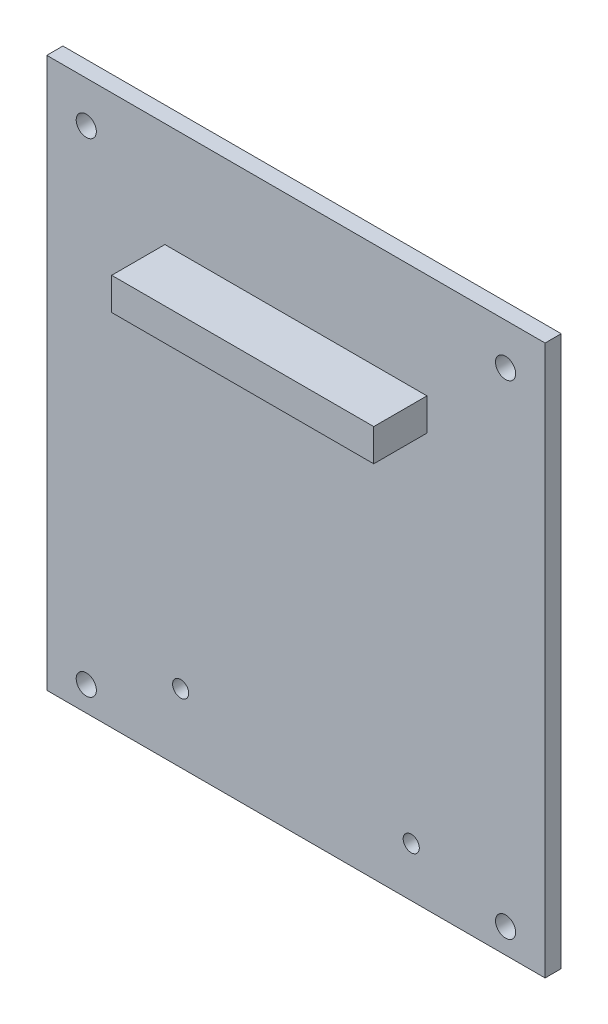
from build123d import *

# Parameters (mm, degrees)
SKETCH1_W           = 78.486
SKETCH1_H           = 86.614
SKETCH1_R           = 1.5875
BOSS_EXTRUDE1_DEPTH = 2.54
SKETCH2_W           = 41.275
SKETCH2_H           = 5.08
BOSS_EXTRUDE2_DEPTH = 8.382
SKETCH4_R           = 1.27
CUT_EXTRUDE1_DEPTH  = 2.54


with BuildPart() as part:
    # Sketch1 → Boss-Extrude1 (new body)
    with BuildSketch(Plane.XY):
        with Locations((39.243, 43.307)):
            Rectangle(SKETCH1_W, SKETCH1_H)
        with Locations((6.223, 80.1116)):
            Circle(SKETCH1_R, mode=Mode.SUBTRACT)
        with Locations((72.263, 80.1116)):
            Circle(SKETCH1_R, mode=Mode.SUBTRACT)
        with Locations((72.263, 3.9116)):
            Circle(SKETCH1_R, mode=Mode.SUBTRACT)
        with Locations((6.223, 3.9116)):
            Circle(SKETCH1_R, mode=Mode.SUBTRACT)
    extrude(amount=BOSS_EXTRUDE1_DEPTH)

    # Sketch2 → Boss-Extrude2 (add)
    with BuildSketch(Plane.XY.offset(2.54)):
        with Locations((39.243, 67.564)):
            Rectangle(SKETCH2_W, SKETCH2_H)
    extrude(amount=BOSS_EXTRUDE2_DEPTH)

    # Sketch4 → Cut-Extrude1 (cut)
    with BuildSketch(Plane.XY.offset(2.54)):
        with Locations((21.082, 10.7569)):
            Circle(SKETCH4_R)
        with Locations((57.404, 7.8105)):
            Circle(SKETCH4_R)
    extrude(amount=-CUT_EXTRUDE1_DEPTH, mode=Mode.SUBTRACT)


solid = part.part
